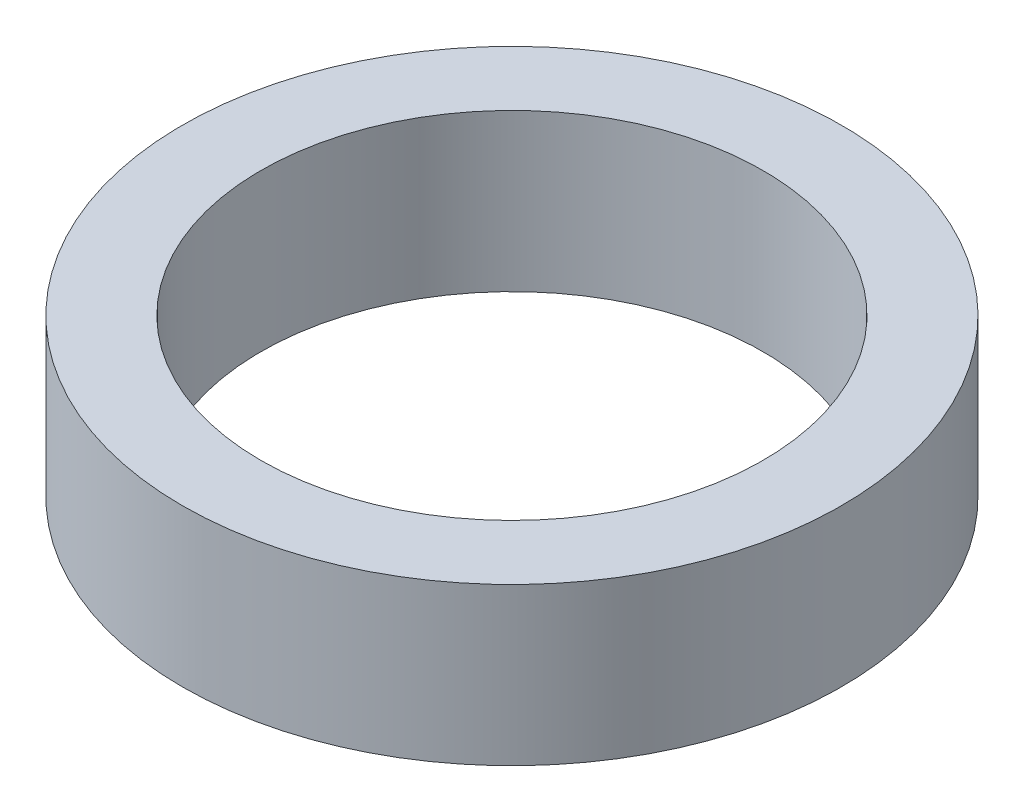
from build123d import *

# Parameters (mm, degrees)
SKETCH1_R           = 2.1
SKETCH1_R_2         = 1.6
BOSS_EXTRUDE1_DEPTH = 1


with BuildPart() as part:
    # Sketch1 → Boss-Extrude1 (new body)
    with BuildSketch(Plane(origin=(0, 0, 0), x_dir=(1, 0, 0), z_dir=(0, 1, 0))):
        Circle(SKETCH1_R)
        Circle(SKETCH1_R_2, mode=Mode.SUBTRACT)
    extrude(amount=BOSS_EXTRUDE1_DEPTH)


solid = part.part
